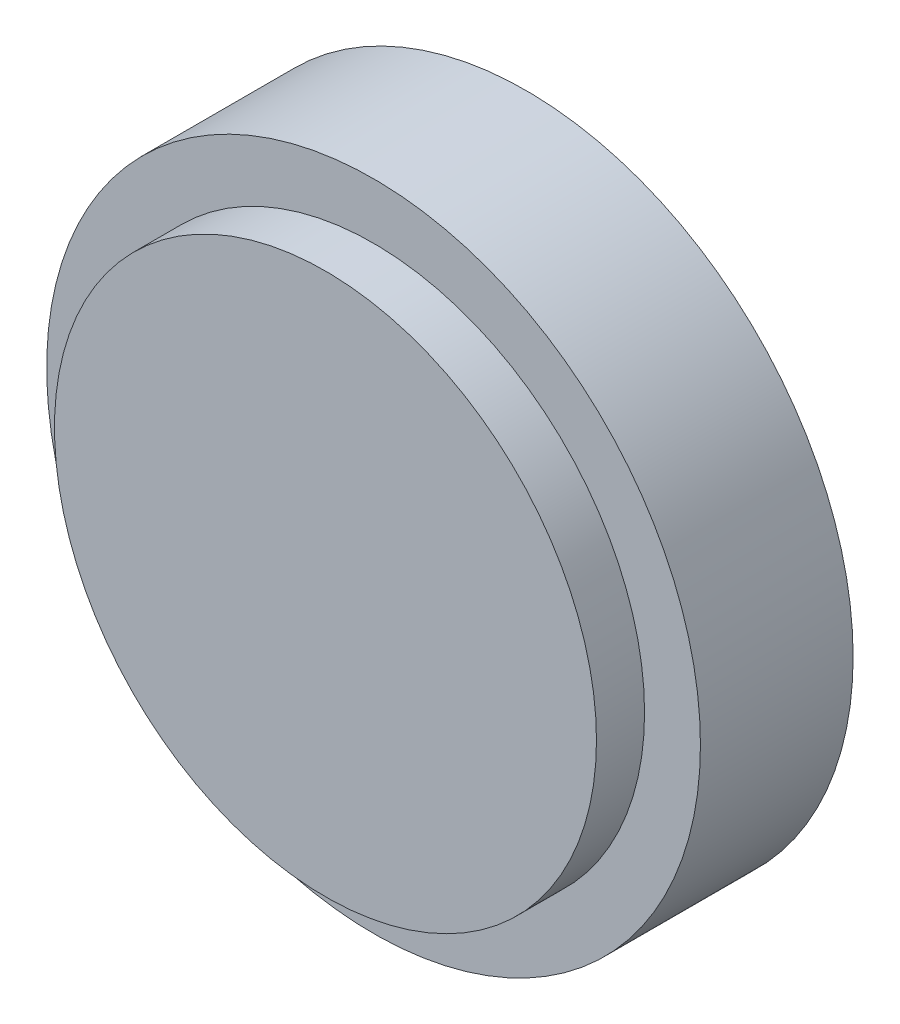
from build123d import *

# Parameters (mm, degrees)
CROQUIS1_R              = 42.82
SALIENTE_EXTRUIR2_DEPTH = 20
CROQUIS1_3_R            = 35.5
SALIENTE_EXTRUIR3_DEPTH = 26.3


with BuildPart() as part:
    # Croquis1 → Saliente-Extruir2 (new body)
    with BuildSketch(Plane.XY):
        Circle(CROQUIS1_R)
    extrude(amount=SALIENTE_EXTRUIR2_DEPTH)

    # Croquis1_3 → Saliente-Extruir3 (add)
    with BuildSketch(Plane.XY):
        Circle(CROQUIS1_3_R)
    extrude(amount=SALIENTE_EXTRUIR3_DEPTH)


solid = part.part
